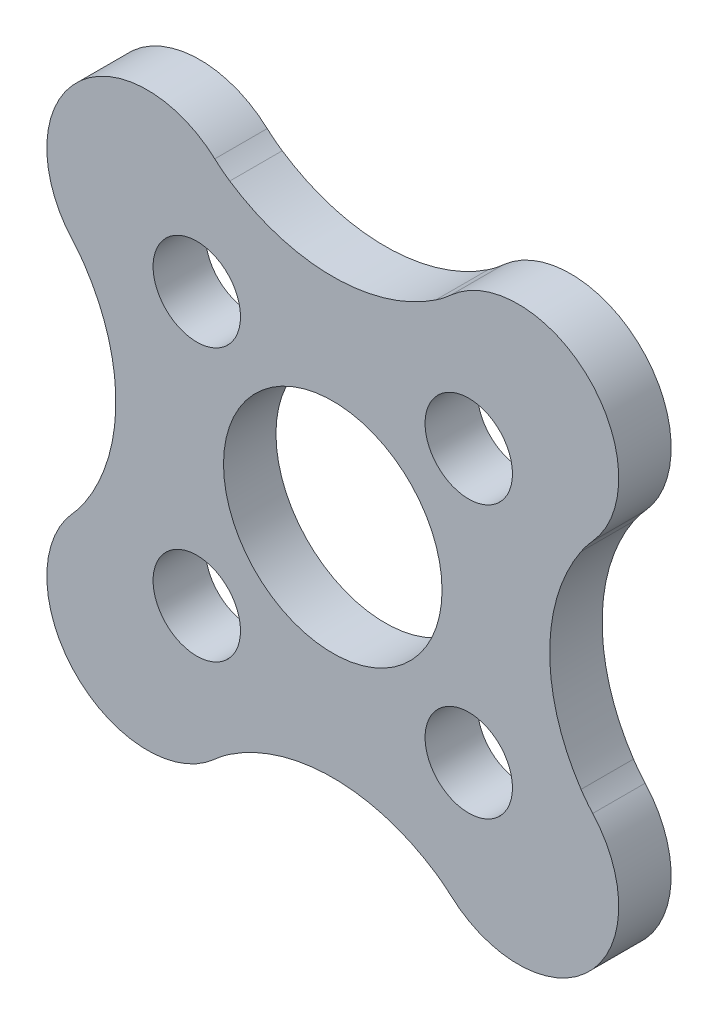
from build123d import *

# Parameters (mm, degrees)
MODEL_R         = 1
MODEL_R_2       = 2.5
EXTRUDE_1_DEPTH = 1.2


with BuildPart() as part:
    # Model → 凸台-拉伸1 (new body)
    with BuildSketch(Plane.XY):
        with BuildLine():
            ThreePointArc((12.485683382, 19.826470809), (12.652302696, 19.686300725), (12.828649886, 19.55858496))
            ThreePointArc((12.828649886, 19.55858496), (15.184787498, 18.84198425), (17.540925109, 19.55858496))
            ThreePointArc((17.540925109, 19.55858496), (17.7172723, 19.686300725), (17.883891613, 19.826470809))
            ThreePointArc((17.883891613, 19.826470809), (21.053773782, 19.747678625), (21.132565966, 16.577796457))
            ThreePointArc((21.132565966, 16.577796457), (20.992395882, 16.411177143), (20.864680117, 16.234829953))
            ThreePointArc((20.864680117, 16.234829953), (20.148079407, 13.878692341), (20.864680117, 11.522554729))
            ThreePointArc((20.864680117, 11.522554729), (20.992395882, 11.346207539), (21.132565966, 11.179588225))
            ThreePointArc((21.132565966, 11.179588225), (21.053773782, 8.009706057), (17.883891613, 7.930913873))
            ThreePointArc((17.883891613, 7.930913873), (17.7172723, 8.071083957), (17.540925109, 8.198799722))
            ThreePointArc((17.540925109, 8.198799722), (15.184787498, 8.915400432), (12.828649886, 8.198799722))
            ThreePointArc((12.828649886, 8.198799722), (12.652302696, 8.071083957), (12.485683382, 7.930913873))
            ThreePointArc((12.485683382, 7.930913873), (9.315801214, 8.009706057), (9.237009029, 11.179588225))
            ThreePointArc((9.237009029, 11.179588225), (9.377179113, 11.346207539), (9.504894878, 11.522554729))
            ThreePointArc((9.504894878, 11.522554729), (10.221495588, 13.878692341), (9.504894878, 16.234829953))
            ThreePointArc((9.504894878, 16.234829953), (9.377179113, 16.411177143), (9.237009029, 16.577796457))
            ThreePointArc((9.237009029, 16.577796457), (9.315801214, 19.747678625), (12.485683382, 19.826470809))
        make_face()
        with Locations((18.296057335, 16.989962178)):
            Circle(MODEL_R, mode=Mode.SUBTRACT)
        with Locations((12.07351766, 16.989962178)):
            Circle(MODEL_R, mode=Mode.SUBTRACT)
        with Locations((12.07351766, 10.767422504)):
            Circle(MODEL_R, mode=Mode.SUBTRACT)
        with Locations((18.296057335, 10.767422504)):
            Circle(MODEL_R, mode=Mode.SUBTRACT)
        with Locations((15.184787498, 13.878692341)):
            Circle(MODEL_R_2, mode=Mode.SUBTRACT)
    extrude(amount=EXTRUDE_1_DEPTH)


solid = part.part
